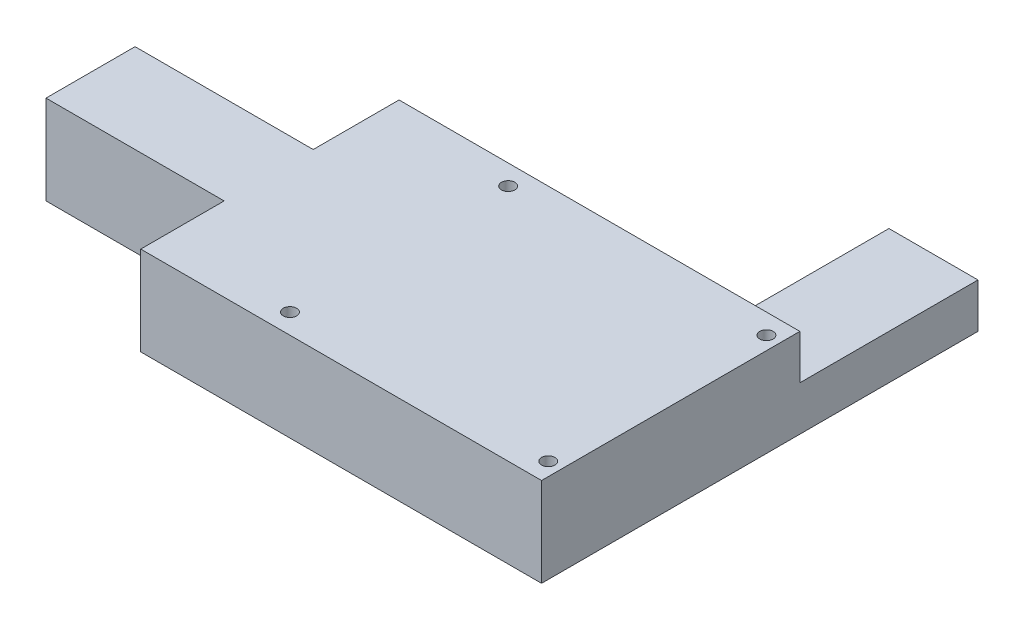
from build123d import *

# Parameters (mm, degrees)
SKETCH1_W           = 90
SKETCH1_H           = 58
BOSS_EXTRUDE1_DEPTH = 20
SKETCH2_R           = 1.5
CUT_EXTRUDE1_DEPTH  = 20
SKETCH3_W           = 20
SKETCH3_H           = 10
BOSS_EXTRUDE2_DEPTH = 40
SKETCH4_W           = 20
SKETCH4_H           = 20
BOSS_EXTRUDE3_DEPTH = 40


with BuildPart() as part:
    # Sketch1 → Boss-Extrude1 (new body)
    with BuildSketch(Plane(origin=(0, 0, 0), x_dir=(1, 0, 0), z_dir=(0, 1, 0))):
        Rectangle(SKETCH1_W, SKETCH1_H)
    extrude(amount=BOSS_EXTRUDE1_DEPTH)

    # Sketch2 → Cut-Extrude1 (cut)
    with BuildSketch(Plane(origin=(0, 20, 0), x_dir=(1, 0, 0), z_dir=(0, 1, 0))):
        with Locations((42, 24.5)):
            Circle(SKETCH2_R)
        with Locations((42, -24.5)):
            Circle(SKETCH2_R)
        with Locations((-16, 24.5)):
            Circle(SKETCH2_R)
        with Locations((-16, -24.5)):
            Circle(SKETCH2_R)
    extrude(amount=-CUT_EXTRUDE1_DEPTH, mode=Mode.SUBTRACT)

    # Sketch3 → Boss-Extrude2 (add)
    with BuildSketch(Plane(origin=(0, 0, -29), x_dir=(-1, 0, 0), z_dir=(0, 0, -1))):
        with Locations((-35, 5)):
            Rectangle(SKETCH3_W, SKETCH3_H)
    extrude(amount=BOSS_EXTRUDE2_DEPTH)

    # Sketch4 → Boss-Extrude3 (add)
    with BuildSketch(Plane.ZY.offset(45)):
        with Locations((0.272543659, 10)):
            Rectangle(SKETCH4_W, SKETCH4_H)
    extrude(amount=BOSS_EXTRUDE3_DEPTH)


solid = part.part
